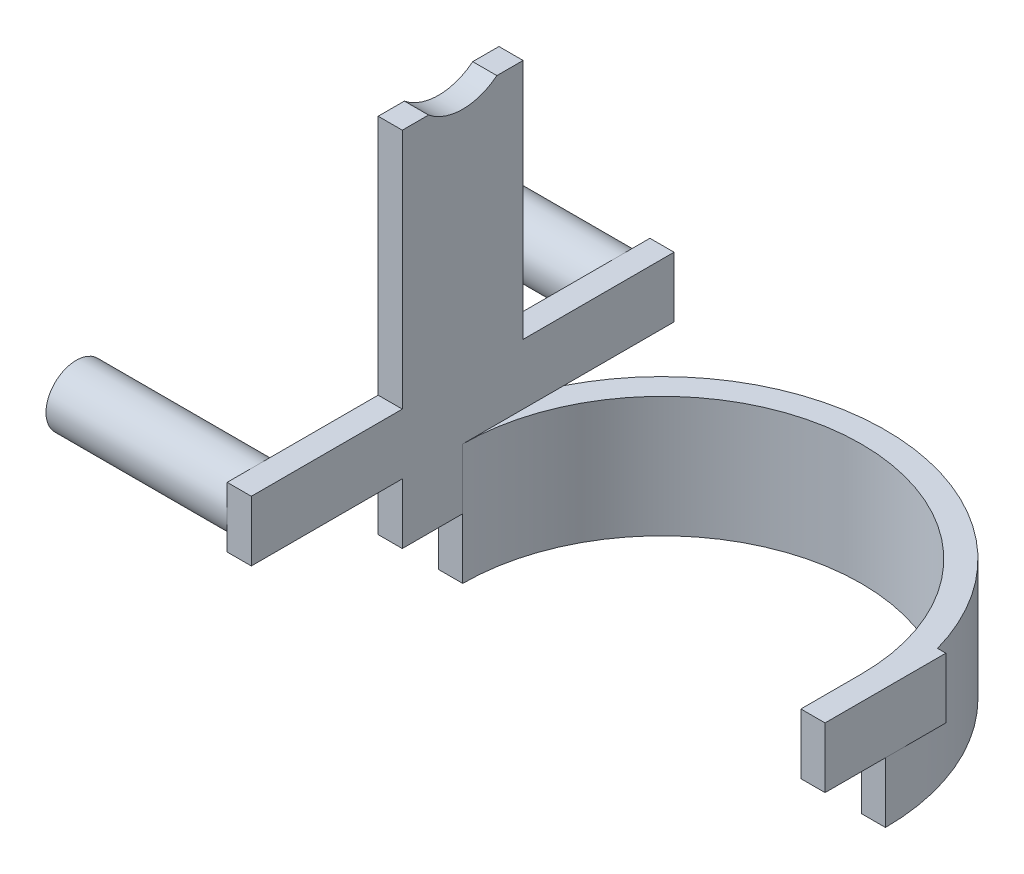
from build123d import *

# Parameters (mm, degrees)
EXTRUDE_1_DEPTH     = 40
SKETCH_2_W          = 8
SKETCH_2_H          = 40
EXTRUDE_2_DEPTH     = 100
SKETCH_3_R          = 18
CUT_EXTRUDE_1_DEPTH = 149
SKETCH_5_W          = 87.00766185
SKETCH_5_H          = 115.01495327
CUT_EXTRUDE_2_DEPTH = 10
SKETCH_6_R          = 85.063361003
CUT_EXTRUDE_3_DEPTH = 20
SKETCH_7_W          = 140
SKETCH_7_H          = 20
EXTRUDE_3_DEPTH     = 8
SKETCH_9_R          = 10
EXTRUDE_4_DEPTH     = 60


with BuildPart() as part:
    # 草图1 → 凸台-拉伸1 (new body)
    with BuildSketch(Plane(origin=(0, 0, 0), x_dir=(1, 0, 0), z_dir=(0, 1, 0))):
        with BuildLine():
            Line((-74, 20), (-71.246052522, 20))
            ThreePointArc((-71.246052522, 20), (0, 74), (71.246052522, 20))
            Line((71.246052522, 20), (74, 20))
            Line((74, 20), (74, -20))
            Line((74, -20), (66, -20))
            Line((66, -20), (66, 0))
            ThreePointArc((66, 0), (0, 66), (-66, 0))
            Line((-66, 0), (-66, -20))
            Line((-66, -20), (-74, -20))
            Line((-74, -20), (-74, 20))
        make_face()
    extrude(amount=EXTRUDE_1_DEPTH)

    # 草图2 → 凸台-拉伸2 (add)
    with BuildSketch(Plane(origin=(0, 40, 0), x_dir=(1, 0, 0), z_dir=(0, 1, 0))):
        with Locations((-70, 0)):
            Rectangle(SKETCH_2_W, SKETCH_2_H)
        with Locations((70, 0)):
            Rectangle(SKETCH_2_W, SKETCH_2_H)
    extrude(amount=EXTRUDE_2_DEPTH)

    # 草图3 → 切除-拉伸1 (cut, through all)
    with BuildSketch(Plane.ZY.offset(74)):
        with Locations((0, 154)):
            Circle(SKETCH_3_R)
    extrude(amount=-CUT_EXTRUDE_1_DEPTH, mode=Mode.SUBTRACT)

    # 草图5 → 切除-拉伸2 (cut)
    with BuildSketch(Plane(origin=(74, 0, 0), x_dir=(0, 0, -1), z_dir=(1, 0, 0))):
        with Locations((-23.503830925, 97.507476635)):
            Rectangle(SKETCH_5_W, SKETCH_5_H)
    extrude(amount=-CUT_EXTRUDE_2_DEPTH, mode=Mode.SUBTRACT)

    # 草图6 → 切除-拉伸3 (cut)
    with BuildSketch(Plane.XZ):
        Circle(SKETCH_6_R)
        with BuildLine():
            Line((-71.246052522, 20), (-66, 20))
            Line((-66, 20), (-66, 0))
            Line((-66, 0), (-74, 0))
            ThreePointArc((-74, 0), (0, -74), (74, 0))
            Line((74, 0), (66, 0))
            Line((66, 0), (66, 20))
            Line((66, 20), (71.246052522, 20))
            ThreePointArc((71.246052522, 20), (0, 74), (-71.246052522, 20))
        make_face(mode=Mode.SUBTRACT)
    extrude(amount=-CUT_EXTRUDE_3_DEPTH, mode=Mode.SUBTRACT)

    # 草图7 → 凸台-拉伸3 (add)
    with BuildSketch(Plane.ZY.offset(74)):
        with Locations((0, 50)):
            Rectangle(SKETCH_7_W, SKETCH_7_H)
    extrude(amount=-EXTRUDE_3_DEPTH)

    # 草图9 → 凸台-拉伸4 (add)
    with BuildSketch(Plane.ZY.offset(74)):
        with Locations((-60, 50)):
            Circle(SKETCH_9_R)
        with Locations((60, 50)):
            Circle(SKETCH_9_R)
    extrude(amount=EXTRUDE_4_DEPTH)


solid = part.part
